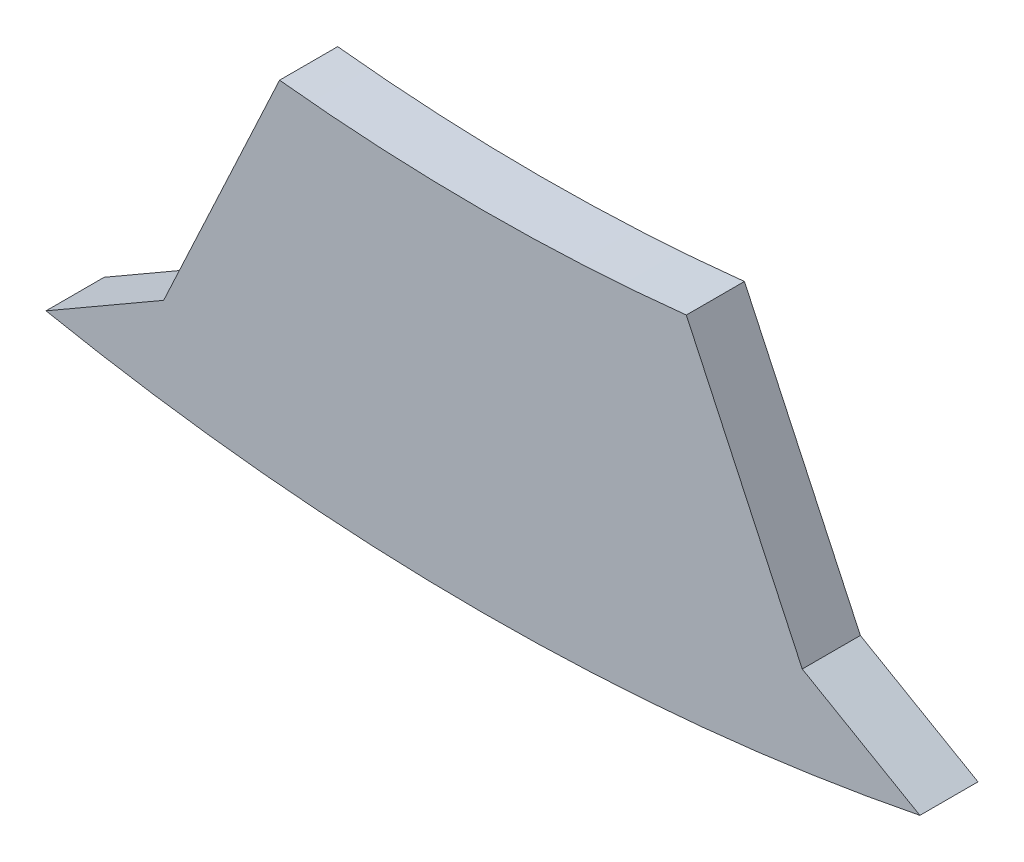
from build123d import *

# Parameters (mm, degrees)
BOSS_EXTRUDE1_DEPTH = 1
SCALE1_SCALE        = 0.97


with BuildPart() as part:
    # Sketch1 → Boss-Extrude1 (new body)
    with BuildSketch(Plane.XY):
        with BuildLine():
            Line((-5.495175992, -36.589657566), (-3.5, -32.310988843))
            ThreePointArc((-3.5, -32.310988843), (0, -32.5), (3.5, -32.310988843))
            Line((3.5, -32.310988843), (5.495175992, -36.589657566))
            Line((5.495175992, -36.589657566), (7.519674459, -37.758502301))
            ThreePointArc((7.519674459, -37.758502301), (0, -38.5), (-7.519674459, -37.758502301))
            Line((-7.519674459, -37.758502301), (-5.495175992, -36.589657566))
        make_face()
    extrude(amount=BOSS_EXTRUDE1_DEPTH)


with BuildPart() as part_1:
    # Scale1: scaled about (0, -35.722317189, 0.5)
    add(part.part.scale(SCALE1_SCALE).moved(Location((0, -1.071669516, 0.015))))


solid = part_1.part
